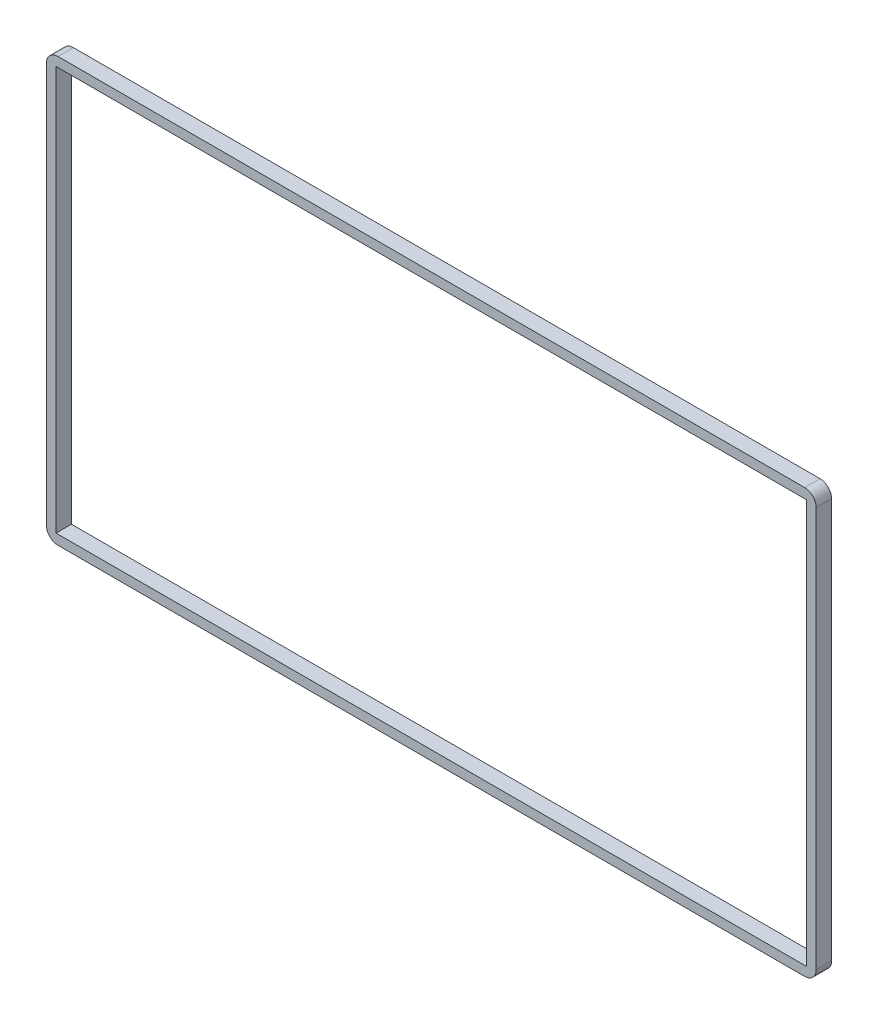
from build123d import *

# Parameters (mm, degrees)
SKETCH1_W           = 100
SKETCH1_H           = 55
SKETCH1_W_2         = 97.5
SKETCH1_H_2         = 52.5
BOSS_EXTRUDE1_DEPTH = 2
FILLET1_R           = 1.5


with BuildPart() as part:
    # Sketch1 → Boss-Extrude1 (new body)
    with BuildSketch(Plane.XY):
        with Locations((12.10302883, 11.151503687)):
            Rectangle(SKETCH1_W, SKETCH1_H)
        with Locations((12.10302883, 11.151503687)):
            Rectangle(SKETCH1_W_2, SKETCH1_H_2, mode=Mode.SUBTRACT)
    extrude(amount=BOSS_EXTRUDE1_DEPTH)

    # Fillet1
    fillet1_edges = [part.edges().sort_by_distance(p)[0] for p in [
        (-37.89697117, 38.651503687, 1),
        (62.10302883, 38.651503687, 1),
        (62.10302883, -16.348496313, 1),
        (-37.89697117, -16.348496313, 1),
    ]]
    fillet(fillet1_edges, radius=FILLET1_R)


solid = part.part
